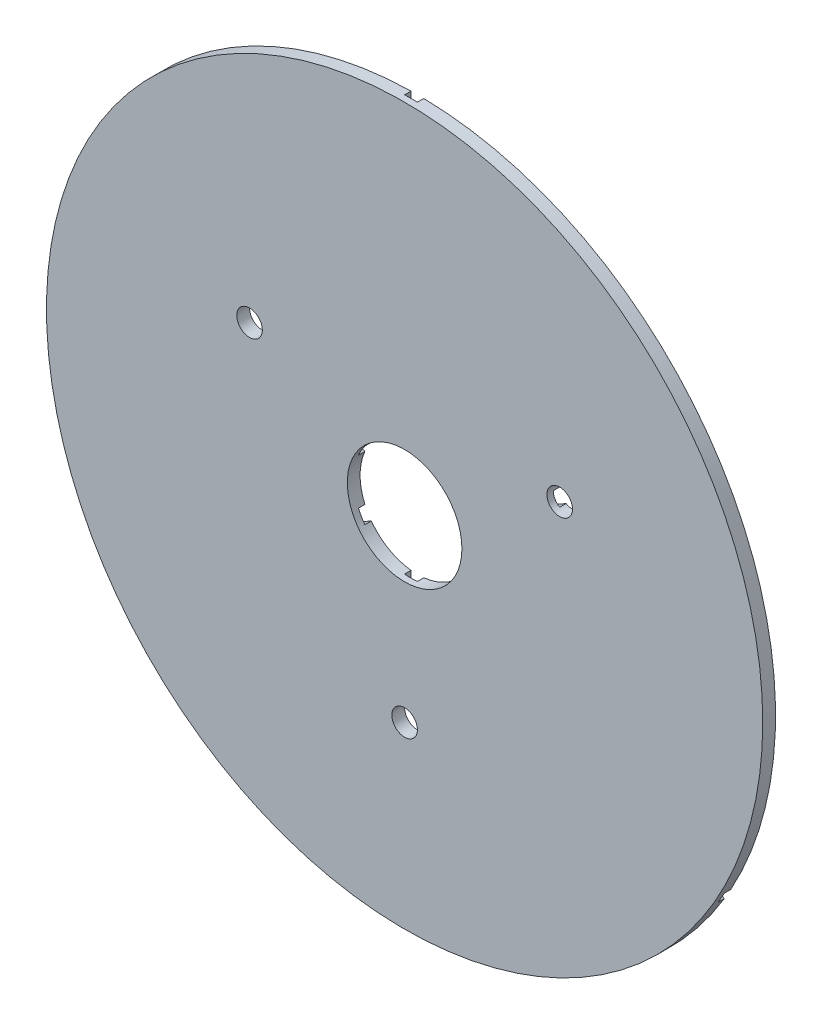
from build123d import *

# Parameters (mm, degrees)
SKETCH1_R           = 88.9
BOSS_EXTRUDE1_DEPTH = 3.175
CUT_EXTRUDE3_DEPTH  = 1.5875
SKETCH3_R           = 14.224
CUT_EXTRUDE4_DEPTH  = 126.763669734
SKETCH2_4_R         = 3.175
CUT_EXTRUDE5_DEPTH  = 126.763669734


with BuildPart() as part:
    # Sketch1 → Boss-Extrude1 (new body)
    with BuildSketch(Plane.XY):
        Circle(SKETCH1_R)
    extrude(amount=BOSS_EXTRUDE1_DEPTH)

    # Sketch2 → Cut-Extrude3 (cut)
    with BuildSketch(Plane(origin=(0, 0, 0), x_dir=(-1, 0, 0), z_dir=(0, 0, -1))):
        with BuildLine():
            ThreePointArc((-77.771132281, -43.068097053), (-76.989658396, -44.45), (-76.183632281, -45.81772771))
            Line((-76.183632281, -45.81772771), (-1.5875, -2.749630657))
            Line((-1.5875, -2.749630657), (-1.5875, -41.700369343))
            ThreePointArc((-1.5875, -41.700369343), (0, -41.275), (1.5875, -41.700369343))
            Line((1.5875, -41.700369343), (1.5875, -2.749630657))
            Line((1.5875, -2.749630657), (76.183632281, -45.81772771))
            ThreePointArc((76.183632281, -45.81772771), (76.989658396, -44.45), (77.771132281, -43.068097053))
            Line((77.771132281, -43.068097053), (3.175, 0))
            Line((3.175, 0), (36.907329198, 19.475369343))
            ThreePointArc((36.907329198, 19.475369343), (35.745198541, 20.6375), (35.319829198, 22.225))
            Line((35.319829198, 22.225), (1.5875, 2.749630657))
            Line((1.5875, 2.749630657), (1.5875, 88.885824763))
            ThreePointArc((1.5875, 88.885824763), (0, 88.9), (-1.5875, 88.885824763))
            Line((-1.5875, 88.885824763), (-1.5875, 2.749630657))
            Line((-1.5875, 2.749630657), (-35.319829198, 22.225))
            ThreePointArc((-35.319829198, 22.225), (-35.745198541, 20.6375), (-36.907329198, 19.475369343))
            Line((-36.907329198, 19.475369343), (-3.175, 0))
            Line((-3.175, 0), (-77.771132281, -43.068097053))
        make_face()
    extrude(amount=-CUT_EXTRUDE3_DEPTH, mode=Mode.SUBTRACT)

    # Sketch3 → Cut-Extrude4 (cut, through all)
    with BuildSketch(Plane.XY.offset(3.175)):
        Circle(SKETCH3_R)
    extrude(amount=-CUT_EXTRUDE4_DEPTH, mode=Mode.SUBTRACT)

    # Sketch2_4 → Cut-Extrude5 (cut, through all)
    with BuildSketch(Plane(origin=(0, 0, 0), x_dir=(-1, 0, 0), z_dir=(0, 0, -1))):
        with Locations((0, -44.45)):
            Circle(SKETCH2_4_R)
        with Locations((-38.494829198, 22.225)):
            Circle(SKETCH2_4_R)
        with Locations((38.494829198, 22.225)):
            Circle(SKETCH2_4_R)
    extrude(amount=-CUT_EXTRUDE5_DEPTH, mode=Mode.SUBTRACT)


solid = part.part
